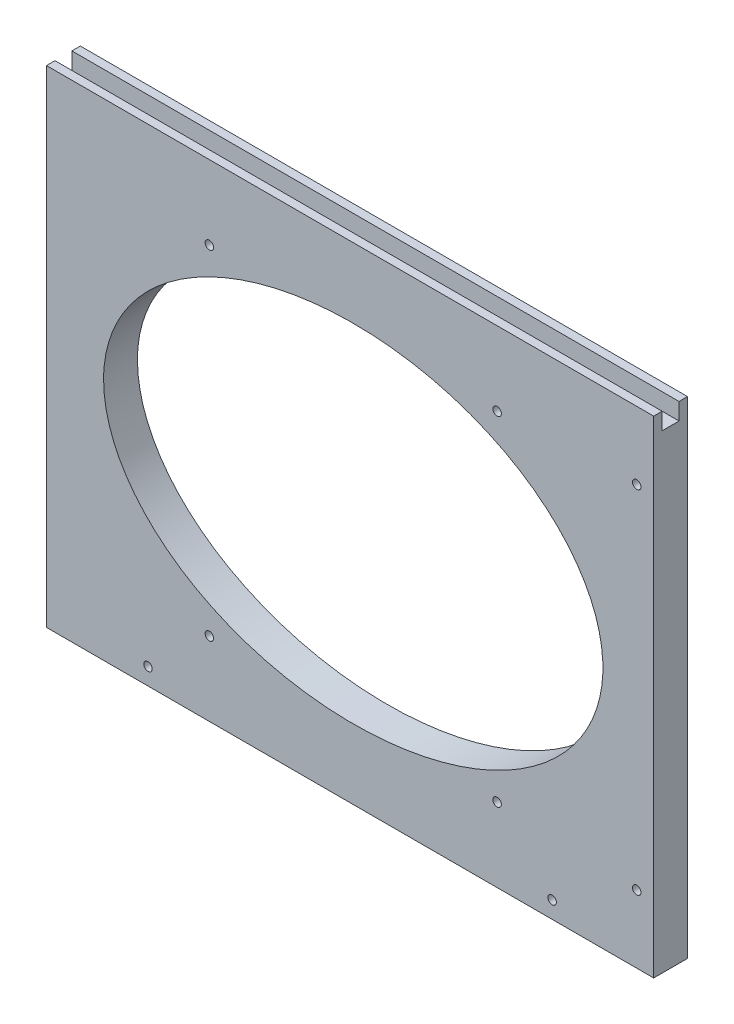
from build123d import *

# Parameters (mm, degrees)
SKETCH2_W          = 227.80625
SKETCH2_H          = 182.5625
EXTRUDE1_DEPTH     = 12.7
SKETCH4_R          = 1.5875
SKETCH4_RX         = 93.6625
SKETCH4_RY         = 65.087499997
CUT_EXTRUDE1_DEPTH = 12.7
CUT_EXTRUDE2_DEPTH = 227.80625


with BuildPart() as part:
    # Sketch2 → Extrude1 (new body)
    with BuildSketch(Plane.XY):
        with Locations((-5626.496875, 1089.81875)):
            Rectangle(SKETCH2_W, SKETCH2_H)
    extrude(amount=-EXTRUDE1_DEPTH)

    # Sketch4 → Cut-Extrude1 (cut)
    with BuildSketch(Plane.XY):
        with Locations((-5571.33125, 1153.31875)):
            Circle(SKETCH4_R)
        with Locations((-5518.94375, 1155.7)):
            Circle(SKETCH4_R)
        with Locations((-5518.94375, 1023.9375)):
            Circle(SKETCH4_R)
        with Locations((-5550.69375, 1004.8875)):
            Circle(SKETCH4_R)
        with Locations((-5571.33125, 1026.31875)):
            Circle(SKETCH4_R)
        with Locations((-5679.28125, 1026.31875)):
            Circle(SKETCH4_R)
        with Locations((-5702.3, 1004.8875)):
            Circle(SKETCH4_R)
        with Locations((-5679.28125, 1153.31875)):
            Circle(SKETCH4_R)
        with Locations(Location((-5625.30625, 1089.81875), (0, 0, 180))):
            Ellipse(SKETCH4_RX, SKETCH4_RY)
    extrude(amount=-CUT_EXTRUDE1_DEPTH, mode=Mode.SUBTRACT)

    # Sketch5 → Cut-Extrude2 (cut)
    with BuildSketch(Plane(origin=(-5512.59375, 0, 0), x_dir=(0, 0, -1), z_dir=(1, 0, 0))):
        Polygon((6.35, 1181.1), (3.175, 1181.1), (3.175, 1174.75), (9.525, 1174.75), (9.525, 1181.1), align=None)
    extrude(amount=-CUT_EXTRUDE2_DEPTH, mode=Mode.SUBTRACT)


solid = part.part
